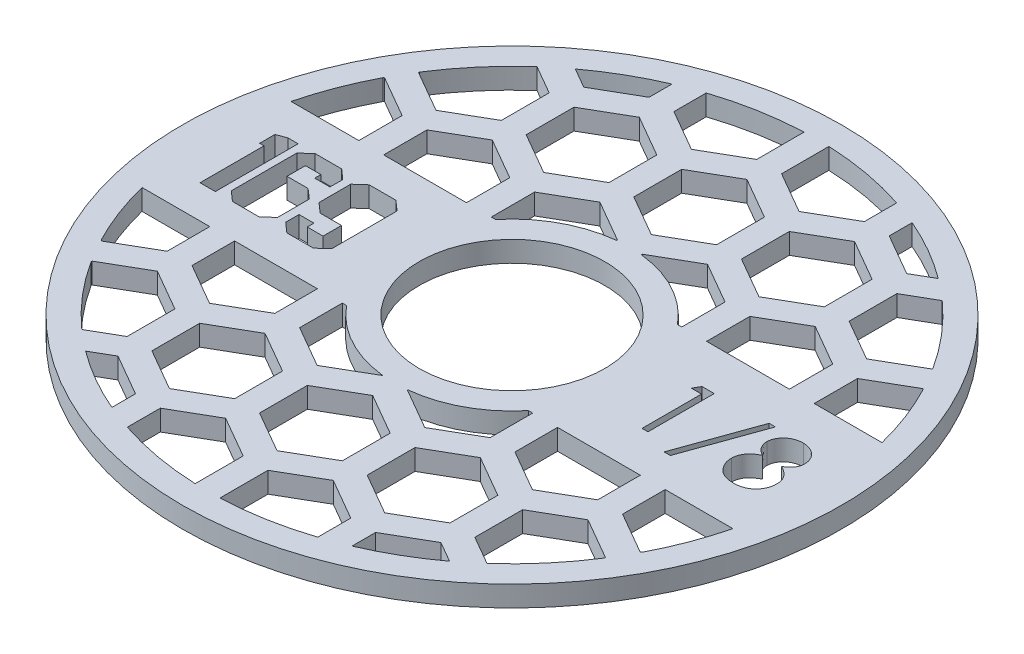
from build123d import *

# Parameters (mm, degrees)
SKETCH1_R               = 50.546
SKETCH1_R_2             = 14.224
BOSS_EXTRUDE1_DEPTH     = 3.175
CUT_EXTRUDE1_DEPTH      = 1
CUT_EXTRUDE1_DEPTH_BACK = 4.175
CUT_EXTRUDE2_DEPTH      = 1.0000001
CUT_EXTRUDE2_DEPTH_BACK = 4.1750001


with BuildPart() as part:
    # Sketch1 → Boss-Extrude1 (new body)
    with BuildSketch(Plane(origin=(0, 0, 0), x_dir=(1, 0, 0), z_dir=(0, 1, 0))):
        Circle(SKETCH1_R)
        Circle(SKETCH1_R_2, mode=Mode.SUBTRACT)
    extrude(amount=BOSS_EXTRUDE1_DEPTH)

    # Sketch2 → Cut-Extrude1 (cut, two sides)
    with BuildSketch(Plane(origin=(0, 3.175, 0), x_dir=(1, 0, 0), z_dir=(0, 1, 0))) as cut_extrude1_sk:
        Polygon((-22.636037344, -5.022991324), (-24.137904564, -6.35), (-28.181208978, -6.35), (-29.68547152, -5.022991324), (-29.68547152, -2.979781215), (-27.397938514, -2.979781215), (-27.397938514, -4.004979253), (-24.978662769, -4.004979253), (-24.978662769, -1.176103357), (-28.253068653, -1.176103357), (-29.750145228, 0.150905319), (-29.750145228, 5.015805356), (-28.253068653, 6.35), (-24.154671822, 6.35), (-22.636037344, 5.008619389), align=None)
        Polygon((-30.945411166, -5.022991324), (-32.449673708, -6.35), (-36.524117314, -6.35), (-38.028379857, -5.022991324), (-38.028379857, 5.015805356), (-36.540884572, 6.35), (-32.473626933, 6.35), (-30.969364391, 5.015805356), (-30.969364391, 3.05164089), (-33.321571105, 3.05164089), (-33.321571105, 4.004979253), (-35.68335911, 4.004979253), (-35.68335911, 1.176103357), (-32.449673708, 1.176103357), (-30.945411166, -0.141324029), align=None)
        Polygon((-39.151786118, -6.35), (-41.496806865, -6.35), (-41.496806865, 3.463636364), (-42.167497171, 3.463636364), (-42.167497171, 5.808657111), (-40.720722369, 6.35), (-39.151786118, 6.35), align=None)
        Polygon((24.058766026, 5.08), (25.937307692, 5.08), (25.937307692, -5.08), (25.025512821, -5.08), (25.025512821, 4.037948718), (23.462435897, 4.037948718), align=None)
        Polygon((35.05525641, 5.340512821), (30.805641026, -6.512820513), (29.845, -6.512820513), (34.094615385, 5.340512821), align=None)
        with BuildLine():
            add(Edge.make_bspline(
                [(40.776362179, 0.580048077), (40.859524819, 0.536685325), (41.02171974, 0.452113476), (41.252721008, 0.315938045), (41.463831297, 0.172417987), (41.660907899, 0.028332178), (41.840488369, -0.121837416), (42.000564722, -0.278687949), (42.14509107, -0.438304293), (42.27115282, -0.603389315), (42.38203278, -0.773504433), (42.477862293, -0.949096152), (42.559772801, -1.129779658), (42.624689218, -1.317527256), (42.678165047, -1.509581044), (42.714960518, -1.7084209), (42.734749057, -1.912736586), (42.738490298, -2.050820571), (42.740384615, -2.120737179)],
                knots=[0, 0, 0, 0, 0.000281344, 0.000548715, 0.000803862, 0.001046877, 0.001280887, 0.001505412, 0.001718716, 0.001926323, 0.002127854, 0.00232732, 0.002525911, 0.002722237, 0.002922697, 0.003123487, 0.003328028, 0.003537817, 0.003537817, 0.003537817, 0.003537817], degree=3))
            add(Edge.make_bspline(
                [(42.740384615, -2.120737179), (42.738145292, -2.218556883), (42.73371283, -2.412178781), (42.695104876, -2.697953779), (42.637300345, -2.975501123), (42.552886675, -3.244759965), (42.443410089, -3.504244546), (42.308494473, -3.754176985), (42.155771661, -3.998653608), (42.033119446, -4.149077928), (41.971057692, -4.225192308)],
                knots=[0, 0, 0, 0, 0.000293331, 0.000580613, 0.00086363, 0.001143002, 0.001425749, 0.001707093, 0.001994468, 0.002288822, 0.002288822, 0.002288822, 0.002288822], degree=3))
            add(Edge.make_bspline(
                [(41.971057692, -4.225192308), (41.890252384, -4.314001664), (41.729640301, -4.490522934), (41.454499003, -4.719705856), (41.152538334, -4.912308669), (40.824926717, -5.069271654), (40.472539886, -5.19144089), (40.095452924, -5.2792306), (39.692930697, -5.329515137), (39.416272529, -5.336783861), (39.274342949, -5.340512821)],
                knots=[0, 0, 0, 0, 0.00035989, 0.000715332, 0.001070453, 0.001431842, 0.001802594, 0.002187171, 0.002591332, 0.003017095, 0.003017095, 0.003017095, 0.003017095], degree=3))
            add(Edge.make_bspline(
                [(39.274342949, -5.340512821), (39.137869798, -5.337167342), (38.872306908, -5.33065738), (38.485768612, -5.286550115), (38.125457072, -5.209253222), (37.789277278, -5.103459728), (37.479255929, -4.965834608), (37.196276412, -4.794541627), (36.936255967, -4.596475498), (36.707085632, -4.365947774), (36.503628892, -4.119036922), (36.32490563, -3.864306534), (36.17635459, -3.601733359), (36.050582222, -3.335232591), (35.954300191, -3.061068897), (35.887615146, -2.780652859), (35.845264451, -2.494474273), (35.839629614, -2.301342388), (35.836794872, -2.204182692)],
                knots=[0, 0, 0, 0, 0.00040941, 0.000796671, 0.00116512, 0.001513339, 0.001852245, 0.002179997, 0.002503628, 0.002830317, 0.003152666, 0.003462627, 0.003762528, 0.004056635, 0.004345649, 0.004632454, 0.004920283, 0.005211673, 0.005211673, 0.005211673, 0.005211673], degree=3))
            add(Edge.make_bspline(
                [(35.836794872, -2.204182692), (35.838472378, -2.132890866), (35.841787722, -1.991993055), (35.864734367, -1.783831119), (35.901625215, -1.581222911), (35.951726952, -1.383420066), (36.01962776, -1.191862635), (36.101610638, -1.005642974), (36.197207392, -0.824550847), (36.307751574, -0.647595924), (36.436354021, -0.477257683), (36.58197193, -0.31064531), (36.747515686, -0.150344118), (36.931143633, 0.005604407), (37.130757267, 0.159966662), (37.351541413, 0.304400434), (37.587643173, 0.449130983), (37.755444008, 0.535660294), (37.841522436, 0.580048077)],
                knots=[0, 0, 0, 0, 0.000213857, 0.000422657, 0.000627451, 0.000831322, 0.001034083, 0.001236394, 0.001441238, 0.001647914, 0.001861616, 0.002080839, 0.00231112, 0.002552184, 0.002803347, 0.003067523, 0.003343268, 0.003633711, 0.003633711, 0.003633711, 0.003633711], degree=3))
            add(Edge.make_bspline(
                [(37.841522436, 0.580048077), (37.723691474, 0.644302148), (37.495537751, 0.768716015), (37.19343903, 0.997306743), (36.933950821, 1.244885086), (36.724205697, 1.516679004), (36.559113744, 1.804197931), (36.445848309, 2.105642961), (36.369223087, 2.415424593), (36.361632617, 2.627060866), (36.357820513, 2.733349359)],
                knots=[0, 0, 0, 0, 0.000402147, 0.00077867, 0.001132746, 0.001475117, 0.001805061, 0.002123317, 0.002438788, 0.002757076, 0.002757076, 0.002757076, 0.002757076], degree=3))
            add(Edge.make_bspline(
                [(36.357820513, 2.733349359), (36.362567915, 2.841618843), (36.372111022, 3.059259387), (36.449278604, 3.383236019), (36.575030569, 3.701437248), (36.746069806, 4.012320803), (36.959102411, 4.305364855), (37.214688955, 4.568192287), (37.506725954, 4.798422191), (37.833755648, 4.991683309), (38.185687121, 5.14897073), (38.557008193, 5.257474952), (38.941249213, 5.328409508), (39.202790022, 5.336440711), (39.335400641, 5.340512821)],
                knots=[0, 0, 0, 0, 0.000324526, 0.000652354, 0.000993264, 0.001348502, 0.001714062, 0.002076772, 0.002444855, 0.002826361, 0.003213622, 0.003598048, 0.003984522, 0.004382028, 0.004382028, 0.004382028, 0.004382028], degree=3))
            add(Edge.make_bspline(
                [(39.335400641, 5.340512821), (39.464588858, 5.336314293), (39.719333305, 5.328035275), (40.093786281, 5.258985366), (40.452071068, 5.143656246), (40.792952128, 4.987200307), (41.11032692, 4.794488501), (41.390749624, 4.56109625), (41.638457919, 4.299428205), (41.843354332, 4.006473014), (42.012192891, 3.69678404), (42.129761221, 3.372759808), (42.205096094, 3.041401397), (42.214598203, 2.817190506), (42.219358974, 2.704855769)],
                knots=[0, 0, 0, 0, 0.000387346, 0.000763803, 0.001137764, 0.00151389, 0.001886692, 0.002248132, 0.002605226, 0.002964378, 0.003317675, 0.003660227, 0.003995557, 0.004332261, 0.004332261, 0.004332261, 0.004332261], degree=3))
            add(Edge.make_bspline(
                [(42.219358974, 2.704855769), (42.21519465, 2.594614939), (42.207016153, 2.378108215), (42.138218614, 2.062490658), (42.022355967, 1.766915825), (41.864167197, 1.48802977), (41.657990353, 1.230890337), (41.406577573, 0.99222767), (41.111933282, 0.77008122), (40.890558824, 0.644717374), (40.776362179, 0.580048077)],
                knots=[0, 0, 0, 0, 0.000330471, 0.000649026, 0.000963484, 0.001279795, 0.001607187, 0.00194834, 0.002317535, 0.002710909, 0.002710909, 0.002710909, 0.002710909], degree=3))
        make_face()
    extrude(amount=CUT_EXTRUDE1_DEPTH, mode=Mode.SUBTRACT)
    extrude(cut_extrude1_sk.sketch, amount=-CUT_EXTRUDE1_DEPTH_BACK, mode=Mode.SUBTRACT)

    # Sketch3 → Cut-Extrude2 (cut, two sides)
    with BuildSketch(Plane(origin=(0, 3.175, 0), x_dir=(1, 0, 0), z_dir=(0, 1, 0))) as cut_extrude2_sk:
        with BuildLine():
            Line((-45.316760652, 11.43), (-34.925, 11.43))
            Line((-34.925, 11.43), (-34.925, 18.070094793))
            Line((-34.925, 18.070094793), (-41.275, 21.736269002))
            Line((-41.275, 21.736269002), (-41.416615017, 21.654507534))
            ThreePointArc((-41.416615017, 21.654507534), (-43.666975534, 16.656798723), (-45.316760652, 11.43))
        make_face()
        Polygon((-31.115, 11.43), (-18.415, 11.43), (-18.415, 18.070094793), (-24.765, 21.736269002), (-31.115, 18.070094793), align=None)
        with BuildLine():
            ThreePointArc((-31.072970625, 34.910230485), (-35.555600159, 30.332375333), (-39.37, 25.184455444))
            Line((-39.37, 25.184455444), (-39.37, 25.035825791))
            Line((-39.37, 25.035825791), (-33.02, 21.369651581))
            Line((-33.02, 21.369651581), (-26.67, 25.035825791))
            Line((-26.67, 25.035825791), (-26.67, 32.368174209))
            Line((-26.67, 32.368174209), (-31.072970625, 34.910230485))
        make_face()
        with BuildLine():
            ThreePointArc((-18.415, 42.955109952), (-23.281499402, 40.524381323), (-27.832591826, 37.544647132))
            Line((-27.832591826, 37.544647132), (-24.765, 35.773572165))
            Line((-24.765, 35.773572165), (-18.415, 39.439746374))
            Line((-18.415, 39.439746374), (-18.415, 42.955109952))
        make_face()
        Polygon((-22.86, 32.368174209), (-22.86, 25.035825791), (-16.51, 21.369651581), (-10.16, 25.035825791), (-10.16, 32.368174209), (-16.51, 36.034348419), align=None)
        with BuildLine():
            ThreePointArc((-1.905, 46.697159132), (-8.334842466, 45.986781765), (-14.605, 44.395356413))
            Line((-14.605, 44.395356413), (-14.605, 39.439746374))
            Line((-14.605, 39.439746374), (-8.255, 35.773572165))
            Line((-8.255, 35.773572165), (-1.905, 39.439746374))
            Line((-1.905, 39.439746374), (-1.905, 46.697159132))
        make_face()
        Polygon((-6.35, 32.368174209), (-6.35, 25.035825791), (0, 21.369651581), (6.35, 25.035825791), (6.35, 32.368174209), (0, 36.034348419), align=None)
        with BuildLine():
            Line((14.605, 39.439746374), (14.605, 44.395356413))
            ThreePointArc((14.605, 44.395356413), (8.334842466, 45.986781765), (1.905, 46.697159132))
            Line((1.905, 46.697159132), (1.905, 39.439746374))
            Line((1.905, 39.439746374), (8.255, 35.773572165))
            Line((8.255, 35.773572165), (14.605, 39.439746374))
        make_face()
        with BuildLine():
            Line((-14.605, 11.43), (-13.949202701, 11.43))
            ThreePointArc((-13.949202701, 11.43), (-8.568052185, 15.868636922), (-1.905, 17.933101544))
            Line((-1.905, 17.933101544), (-1.905, 18.070094793))
            Line((-1.905, 18.070094793), (-8.255, 21.736269002))
            Line((-8.255, 21.736269002), (-14.605, 18.070094793))
            Line((-14.605, 18.070094793), (-14.605, 11.43))
        make_face()
        with BuildLine():
            ThreePointArc((1.905, 17.933101544), (8.568052185, 15.868636922), (13.949202701, 11.43))
            Line((13.949202701, 11.43), (14.605, 11.43))
            Line((14.605, 11.43), (14.605, 18.070094793))
            Line((14.605, 18.070094793), (8.255, 21.736269002))
            Line((8.255, 21.736269002), (1.905, 18.070094793))
            Line((1.905, 18.070094793), (1.905, 17.933101544))
        make_face()
        Polygon((10.16, 32.368174209), (10.16, 25.035825791), (16.51, 21.369651581), (22.86, 25.035825791), (22.86, 32.368174209), (16.51, 36.034348419), align=None)
        with BuildLine():
            Line((24.765, 35.773572165), (27.832591826, 37.544647132))
            ThreePointArc((27.832591826, 37.544647132), (23.281499402, 40.524381323), (18.415, 42.955109952))
            Line((18.415, 42.955109952), (18.415, 39.439746374))
            Line((18.415, 39.439746374), (24.765, 35.773572165))
        make_face()
        with BuildLine():
            Line((39.37, 25.035825791), (39.37, 25.184455444))
            ThreePointArc((39.37, 25.184455444), (35.555600159, 30.332375333), (31.072970625, 34.910230485))
            Line((31.072970625, 34.910230485), (26.67, 32.368174209))
            Line((26.67, 32.368174209), (26.67, 25.035825791))
            Line((26.67, 25.035825791), (33.02, 21.369651581))
            Line((33.02, 21.369651581), (39.37, 25.035825791))
        make_face()
        Polygon((18.415, 18.070094793), (18.415, 11.43), (31.115, 11.43), (31.115, 18.070094793), (24.765, 21.736269002), align=None)
        with BuildLine():
            Line((34.925, 18.070094793), (34.925, 11.43))
            Line((34.925, 11.43), (45.316760652, 11.43))
            ThreePointArc((45.316760652, 11.43), (43.666975534, 16.656798723), (41.416615017, 21.654507534))
            Line((41.416615017, 21.654507534), (41.275, 21.736269002))
            Line((41.275, 21.736269002), (34.925, 18.070094793))
        make_face()
        with BuildLine():
            Line((45.316760652, -11.43), (34.925, -11.43))
            Line((34.925, -11.43), (34.925, -17.964253626))
            Line((34.925, -17.964253626), (41.275, -21.630427835))
            Line((41.275, -21.630427835), (41.495378195, -21.503192425))
            ThreePointArc((41.495378195, -21.503192425), (43.697301567, -16.577078506), (45.316760652, -11.43))
        make_face()
        Polygon((31.115, -11.43), (18.415, -11.43), (18.415, -17.964253626), (24.765, -21.630427835), (31.115, -17.964253626), align=None)
        with BuildLine():
            ThreePointArc((31.072970625, -34.910230485), (35.555600159, -30.332375333), (39.37, -25.184455444))
            Line((39.37, -25.184455444), (39.37, -25.035825791))
            Line((39.37, -25.035825791), (33.02, -21.369651581))
            Line((33.02, -21.369651581), (26.67, -25.035825791))
            Line((26.67, -25.035825791), (26.67, -32.368174209))
            Line((26.67, -32.368174209), (31.072970625, -34.910230485))
        make_face()
        Polygon((10.16, -25.035825791), (10.16, -32.368174209), (16.51, -36.034348419), (22.86, -32.368174209), (22.86, -25.035825791), (16.51, -21.369651581), align=None)
        with BuildLine():
            Line((14.605, -11.43), (13.949202701, -11.43))
            ThreePointArc((13.949202701, -11.43), (8.568052185, -15.868636922), (1.905, -17.933101544))
            Line((1.905, -17.933101544), (1.905, -17.964253626))
            Line((1.905, -17.964253626), (8.255, -21.630427835))
            Line((8.255, -21.630427835), (14.605, -17.964253626))
            Line((14.605, -17.964253626), (14.605, -11.43))
        make_face()
        Polygon((-6.35, -25.035825791), (-6.35, -32.368174209), (0, -36.034348419), (6.35, -32.368174209), (6.35, -25.035825791), (0, -21.369651581), align=None)
        with BuildLine():
            ThreePointArc((18.415, -42.955109952), (23.324782919, -40.49948392), (27.912754671, -37.485088004))
            Line((27.912754671, -37.485088004), (24.765, -35.667730998))
            Line((24.765, -35.667730998), (18.415, -39.333905207))
            Line((18.415, -39.333905207), (18.415, -42.955109952))
        make_face()
        with BuildLine():
            ThreePointArc((1.954953877, -46.69509451), (8.359438793, -45.982317026), (14.605, -44.395356413))
            Line((14.605, -44.395356413), (14.605, -39.333905207))
            Line((14.605, -39.333905207), (8.255, -35.667730998))
            Line((8.255, -35.667730998), (1.905, -39.333905207))
            Line((1.905, -39.333905207), (1.905, -46.666253626))
            Line((1.905, -46.666253626), (1.954953877, -46.69509451))
        make_face()
        with BuildLine():
            Line((-14.605, -39.333905207), (-14.605, -44.395356413))
            ThreePointArc((-14.605, -44.395356413), (-8.359438793, -45.982317026), (-1.954953877, -46.69509451))
            Line((-1.954953877, -46.69509451), (-1.905, -46.666253626))
            Line((-1.905, -46.666253626), (-1.905, -39.333905207))
            Line((-1.905, -39.333905207), (-8.255, -35.667730998))
            Line((-8.255, -35.667730998), (-14.605, -39.333905207))
        make_face()
        with BuildLine():
            Line((-24.765, -35.667730998), (-27.912754671, -37.485088004))
            ThreePointArc((-27.912754671, -37.485088004), (-23.324782919, -40.49948392), (-18.415, -42.955109952))
            Line((-18.415, -42.955109952), (-18.415, -39.333905207))
            Line((-18.415, -39.333905207), (-24.765, -35.667730998))
        make_face()
        Polygon((-22.86, -25.035825791), (-22.86, -32.368174209), (-16.51, -36.034348419), (-10.16, -32.368174209), (-10.16, -25.035825791), (-16.51, -21.369651581), align=None)
        with BuildLine():
            Line((-39.37, -25.035825791), (-39.37, -25.184455444))
            ThreePointArc((-39.37, -25.184455444), (-35.555600159, -30.332375333), (-31.072970625, -34.910230485))
            Line((-31.072970625, -34.910230485), (-26.67, -32.368174209))
            Line((-26.67, -32.368174209), (-26.67, -25.035825791))
            Line((-26.67, -25.035825791), (-33.02, -21.369651581))
            Line((-33.02, -21.369651581), (-39.37, -25.035825791))
        make_face()
        with BuildLine():
            Line((-34.925, -17.964253626), (-34.925, -11.43))
            Line((-34.925, -11.43), (-45.316760652, -11.43))
            ThreePointArc((-45.316760652, -11.43), (-43.697301567, -16.577078506), (-41.495378195, -21.503192425))
            Line((-41.495378195, -21.503192425), (-41.275, -21.630427835))
            Line((-41.275, -21.630427835), (-34.925, -17.964253626))
        make_face()
        Polygon((-18.415, -17.964253626), (-18.415, -11.43), (-31.115, -11.43), (-31.115, -17.964253626), (-24.765, -21.630427835), align=None)
        with BuildLine():
            ThreePointArc((-1.905, -17.933101544), (-8.568052185, -15.868636922), (-13.949202701, -11.43))
            Line((-13.949202701, -11.43), (-14.605, -11.43))
            Line((-14.605, -11.43), (-14.605, -17.964253626))
            Line((-14.605, -17.964253626), (-8.255, -21.630427835))
            Line((-8.255, -21.630427835), (-1.905, -17.964253626))
            Line((-1.905, -17.964253626), (-1.905, -17.933101544))
        make_face()
    extrude(amount=CUT_EXTRUDE2_DEPTH, mode=Mode.SUBTRACT)
    extrude(cut_extrude2_sk.sketch, amount=-CUT_EXTRUDE2_DEPTH_BACK, mode=Mode.SUBTRACT)


solid = part.part
